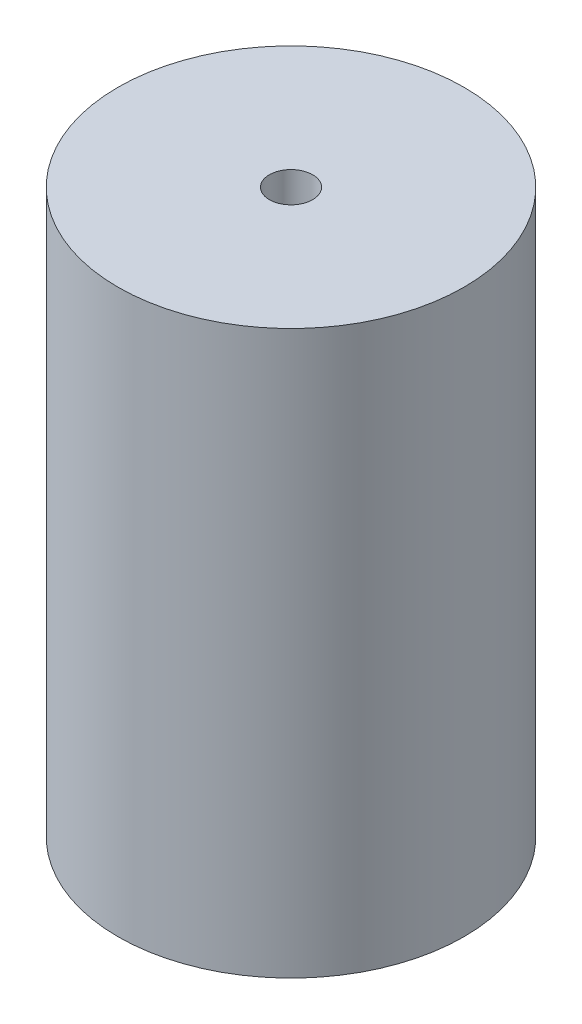
from build123d import *

# Parameters (mm, degrees)
SKETCH1_R           = 50.8
SKETCH1_R_2         = 6.35
BOSS_EXTRUDE1_DEPTH = 165.1


with BuildPart() as part:
    # Sketch1 → Boss-Extrude1 (new body)
    with BuildSketch(Plane(origin=(0, 0, 0), x_dir=(1, 0, 0), z_dir=(0, 1, 0))):
        Circle(SKETCH1_R)
        Circle(SKETCH1_R_2, mode=Mode.SUBTRACT)
    extrude(amount=BOSS_EXTRUDE1_DEPTH)


solid = part.part
